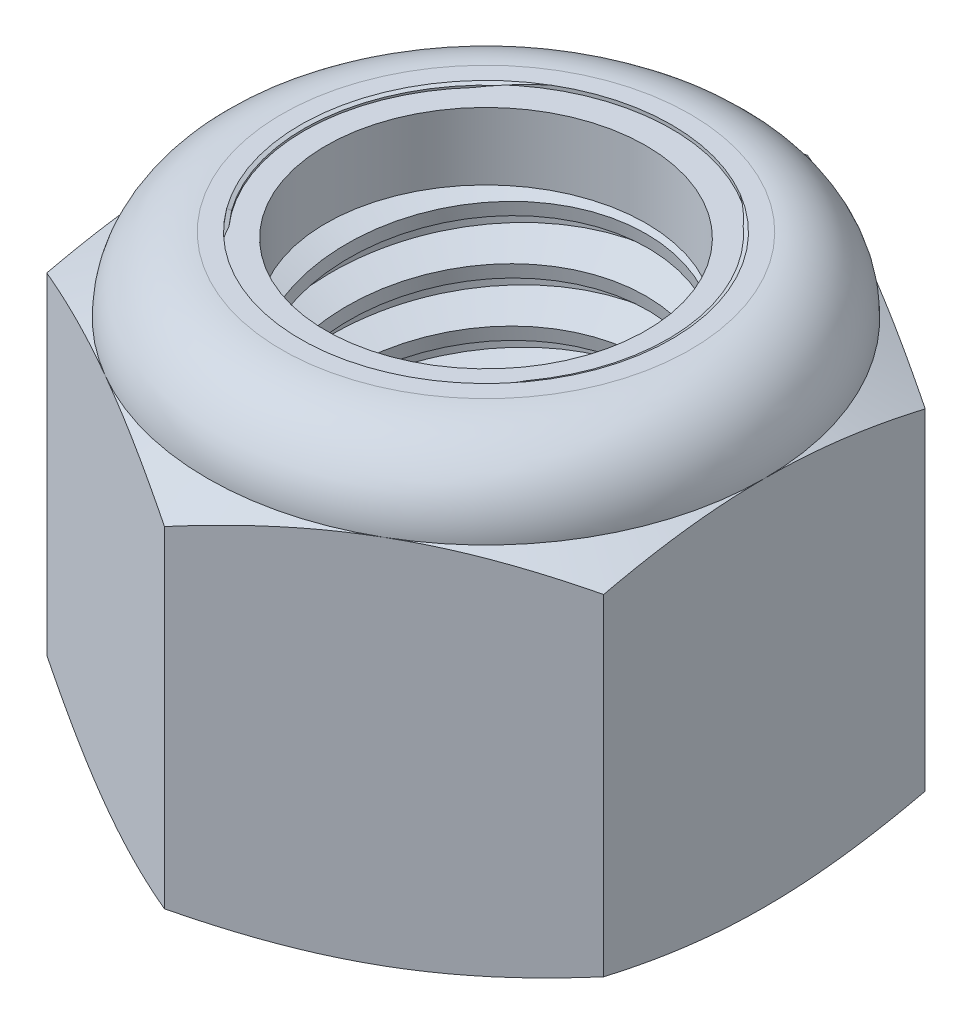
from build123d import *

# Parameters (mm, degrees)
EXTRUDE1_DEPTH      = 19.05
SKETCH2_W           = 7.9375
SKETCH2_H           = 19.05
LPATTERN1_COUNT     = 8
LPATTERN1_PITCH     = 2.309090909
LPATTERN1_COL_COUNT = 2
LPATTERN1_COL_PITCH = 2.309090909


with BuildPart() as part:
    # Sketch1 → Extrude1 (new body)
    with BuildSketch(Plane(origin=(0, 0, 0), x_dir=(1, 0, 0), z_dir=(0, 1, 0))):
        Polygon((0, 13.748153285), (-11.90625, 6.874076643), (-11.90625, -6.874076643), (0, -13.748153285), (11.90625, -6.874076643), (11.90625, 6.874076643), align=None)
    extrude(amount=EXTRUDE1_DEPTH)

    # Sketch4 → Cut-Revolve2 (revolve, cut)
    with BuildSketch(Plane(origin=(0, 0, 0), x_dir=(0, 0, -1), z_dir=(1, 0, 0))):
        Polygon((0, 19.05), (7.9375, 19.05), (6.846095044, 18.541069511), (6.846095044, 0.508930489), (7.9375, 0), (0, 0), align=None)
    revolve(axis=Axis((0, 19.05, 0), (0, 1, 0)), mode=Mode.SUBTRACT)


with BuildPart() as body_2:
    # Sketch2 → Revolve1 (revolve)
    with BuildSketch(Plane(origin=(0, 0, 0), x_dir=(0, 0, -1), z_dir=(1, 0, 0))):
        with Locations((3.96875, 9.525)):
            Rectangle(SKETCH2_W, SKETCH2_H)
    revolve(axis=Axis((0, -7.9375, 0), (0, 1, 0)))

    # Sketch3 → Cut-Revolve1 (revolve, cut)
    with BuildSketch(Plane(origin=(0, 0, 0), x_dir=(0, 0, -1), z_dir=(1, 0, 0))):
        Polygon((7.979046274, 18.764369369), (8.269870189, 16.764954949), (6.929187591, 17.299130886), (6.846095044, 17.870392148), align=None)
    cut_revolve1 = revolve(axis=Axis((0, 19.05, 0.358847596), (0, -0.989586439, -0.143939846)), mode=Mode.SUBTRACT)

    # LPattern1: Cut-Revolve1 ×8
    with Locations(*[(0, -i * LPATTERN1_PITCH, 0) for i in range(1, LPATTERN1_COUNT)]):
        add(cut_revolve1, mode=Mode.SUBTRACT)

    # LPattern1 col: Cut-Revolve1 ×2
    with Locations(*[(0, i * LPATTERN1_COL_PITCH, 0) for i in range(1, LPATTERN1_COL_COUNT)]):
        add(cut_revolve1, mode=Mode.SUBTRACT)


with BuildPart() as part_1:
    add(part.part)

    # Combine1: cut body 2
    add(body_2.part, mode=Mode.SUBTRACT)

    # Sketch5 → Cut-Revolve3 (revolve, cut)
    with BuildSketch(Plane(origin=(0, 0, 0), x_dir=(0, 0, -1), z_dir=(1, 0, 0))):
        with BuildLine():
            Line((0, 0), (11.90625, 0))
            Line((11.90625, 0), (13.748153285, 0.858893607))
            Line((13.748153285, 0.858893607), (13.748153285, 15.016106393))
            Line((13.748153285, 15.016106393), (11.90625, 15.875))
            ThreePointArc((11.90625, 15.875), (10.97631403, 18.12006403), (8.73125, 19.05))
            Line((8.73125, 19.05), (8.73125, 20.32))
            Line((8.73125, 20.32), (15.018153285, 20.32))
            Line((15.018153285, 20.32), (15.018153285, -1.27))
            Line((15.018153285, -1.27), (0, -1.27))
            Line((0, -1.27), (0, 0))
        make_face()
    revolve(axis=Axis((0, 0, 0), (0, 1, 0)), mode=Mode.SUBTRACT)

    # Sketch6 → Cut-Revolve4 (revolve, cut)
    with BuildSketch(Plane(origin=(0, 0, 0), x_dir=(0, 0, -1), z_dir=(1, 0, 0))):
        with BuildLine():
            Line((0, 15.875), (11.75385, 15.875))
            ThreePointArc((11.75385, 15.875), (10.868550957, 18.012300957), (8.73125, 18.8976))
            Line((8.73125, 18.8976), (7.788672522, 18.8976))
            Line((7.788672522, 18.8976), (7.788672522, 20.32))
            Line((7.788672522, 20.32), (0, 20.32))
            Line((0, 20.32), (0, 15.875))
        make_face()
    revolve(axis=Axis((0, 20.32, 0), (0, 1, 0)), mode=Mode.SUBTRACT)


with BuildPart() as body_2_2:
    # Sketch7 → Revolve2 (revolve)
    with BuildSketch(Plane(origin=(0, 0, 0), x_dir=(0, 0, -1), z_dir=(1, 0, 0))):
        with BuildLine():
            Line((6.846095044, 15.9512), (11.67666449, 15.9512))
            ThreePointArc((11.67666449, 15.9512), (10.787552176, 17.985188219), (8.73125, 18.8214))
            Line((8.73125, 18.8214), (6.846095044, 18.8214))
            Line((6.846095044, 18.8214), (6.846095044, 15.9512))
        make_face()
    revolve(axis=Axis((0, 15.9512, 0), (0, 1, 0)))


solid = Compound([part_1.part, body_2_2.part])
